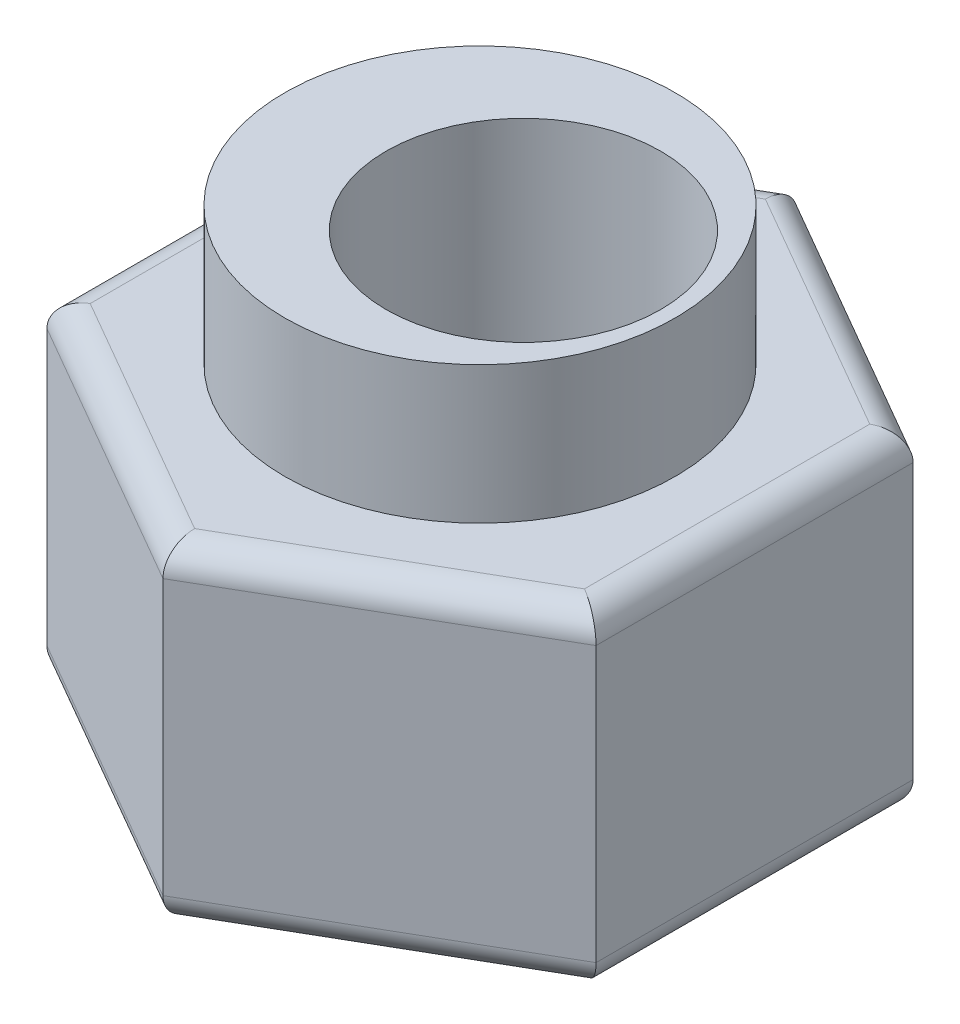
from build123d import *

# Parameters (mm, degrees)
BOSS_EXTRUDE1_DEPTH = 6
SKETCH2_R           = 3.555
BOSS_EXTRUDE2_DEPTH = 2.5
SKETCH3_R           = 2.5
CUT_EXTRUDE1_DEPTH  = 9.5
FILLET1_R           = 0.5


with BuildPart() as part:
    # Sketch1 → Boss-Extrude1 (new body)
    with BuildSketch(Plane(origin=(0, 0, 0), x_dir=(1, 0, 0), z_dir=(0, 1, 0))):
        Polygon((5, -2.886751346), (5, 2.886751346), (0, 5.773502692), (-5, 2.886751346), (-5, -2.886751346), (0, -5.773502692), align=None)
    extrude(amount=BOSS_EXTRUDE1_DEPTH)

    # Sketch2 → Boss-Extrude2 (add)
    with BuildSketch(Plane(origin=(0, 6, 0), x_dir=(1, 0, 0), z_dir=(0, 1, 0))):
        Circle(SKETCH2_R)
    extrude(amount=BOSS_EXTRUDE2_DEPTH)

    # Sketch3 → Cut-Extrude1 (cut, through all)
    with BuildSketch(Plane(origin=(0, 8.5, 0), x_dir=(1, 0, 0), z_dir=(0, 1, 0))):
        with Locations((0.79, 0)):
            Circle(SKETCH3_R)
    extrude(amount=-CUT_EXTRUDE1_DEPTH, mode=Mode.SUBTRACT)

    # Fillet1
    fillet1_edges = [part.edges().sort_by_distance(p)[0] for p in [
        (2.5, 6, -4.330127019),
        (-2.5, 6, -4.330127019),
        (-5, 6, 0),
        (-2.5, 6, 4.330127019),
        (2.5, 6, 4.330127019),
        (-2.5, 0, 4.330127019),
        (-5, 0, 0),
        (-2.5, 0, -4.330127019),
        (2.5, 0, -4.330127019),
        (5, 0, 0),
        (2.5, 0, 4.330127019),
        (5, 6, 0),
    ]]
    fillet(fillet1_edges, radius=FILLET1_R)


solid = part.part
